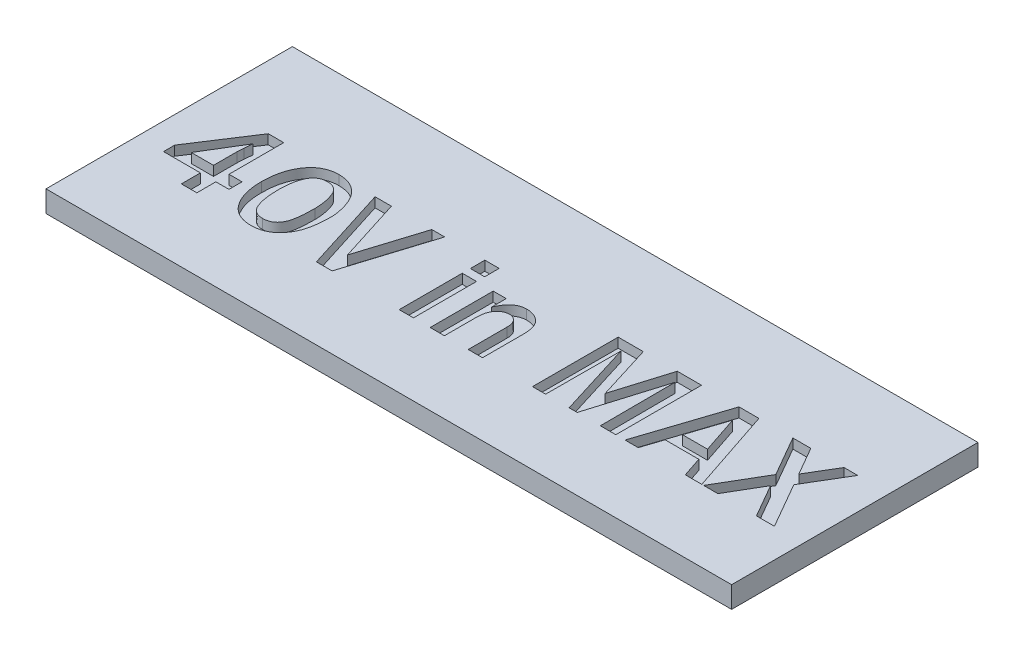
from build123d import *

# Parameters (mm, degrees)
SKETCH1_W           = 32
SKETCH1_H           = 11.5
BOSS_EXTRUDE1_DEPTH = 1
SKETCH2_W           = 0.666666667
SKETCH2_H           = 0.677083333
SKETCH2_H_2         = 2.944444444
CUT_EXTRUDE1_DEPTH  = 0.45


with BuildPart() as part:
    # Sketch1 → Boss-Extrude1 (new body)
    with BuildSketch(Plane(origin=(0, 0, 0), x_dir=(1, 0, 0), z_dir=(0, 1, 0))):
        with Locations((-3.777906977, 3.556976744)):
            Rectangle(SKETCH1_W, SKETCH1_H)
    extrude(amount=BOSS_EXTRUDE1_DEPTH)

    # Sketch2 → Cut-Extrude1 (cut)
    with BuildSketch(Plane(origin=(0, 1, 0), x_dir=(1, 0, 0), z_dir=(0, 1, 0))):
        Polygon((-16.097653065, 1.166505998), (-16.819875288, 1.166505998), (-16.819875288, 2.055394887), (-18.54209751, 2.055394887), (-18.54209751, 2.578832387), (-16.819875288, 5.222061553), (-16.097653065, 5.222061553), (-16.097653065, 2.666505998), (-15.486541954, 2.666505998), (-15.486541954, 2.055394887), (-16.097653065, 2.055394887), align=None)
        with BuildLine():
            Line((-16.766923899, 4.458172665), (-17.857201677, 2.666505998))
            Line((-17.857201677, 2.666505998), (-16.819875288, 2.666505998))
            Line((-16.819875288, 2.666505998), (-16.819875288, 3.762860165))
            add(Edge.make_bspline(
                [(-16.819875288, 3.762860165), (-16.819319866, 3.818177081), (-16.818265444, 3.923191713), (-16.807573902, 4.027658042), (-16.802514177, 4.077096276)],
                knots=[0, 0, 0, 0, 0.000165855, 0.000314863, 0.000314863, 0.000314863, 0.000314863], degree=3))
            Line((-16.802514177, 4.077096276), (-16.766923899, 4.458172665))
        make_face(mode=Mode.SUBTRACT)
        with BuildLine():
            add(Edge.make_bspline(
                [(-13.525604454, 1.110950442), (-13.58475032, 1.112416739), (-13.69993031, 1.115272188), (-13.867311675, 1.143345758), (-14.024764425, 1.186921434), (-14.171217374, 1.250090903), (-14.307963868, 1.329793669), (-14.433242579, 1.428538986), (-14.547587952, 1.545551389), (-14.651419625, 1.678072498), (-14.742591078, 1.825250167), (-14.823443277, 1.982113771), (-14.891702778, 2.14905314), (-14.945532916, 2.325724063), (-14.989431197, 2.511490669), (-15.020377902, 2.707022486), (-15.038743335, 2.912388636), (-15.040963905, 3.052463013), (-15.04209751, 3.123971276)],
                knots=[0, 0, 0, 0, 0.000177296, 0.000345264, 0.000507665, 0.000666327, 0.00082235, 0.000981242, 0.001143292, 0.001312081, 0.001485251, 0.001661896, 0.001840987, 0.002025493, 0.002215415, 0.002413212, 0.002618882, 0.002833378, 0.002833378, 0.002833378, 0.002833378], degree=3))
            add(Edge.make_bspline(
                [(-15.04209751, 3.123971276), (-15.041153805, 3.20098927), (-15.039309128, 3.351537844), (-15.018441162, 3.571240529), (-14.987038215, 3.77960434), (-14.94187967, 3.976378482), (-14.884131081, 4.161821209), (-14.81238597, 4.335226182), (-14.7295261, 4.497836364), (-14.632240218, 4.646553801), (-14.525090061, 4.781236686), (-14.408509436, 4.899747852), (-14.281974225, 4.999121269), (-14.146817076, 5.080985248), (-14.002752645, 5.14478328), (-13.849577359, 5.189838493), (-13.687781108, 5.217541971), (-13.576932061, 5.22053502), (-13.520396121, 5.222061553)],
                knots=[0, 0, 0, 0, 0.000230983, 0.000451506, 0.000661443, 0.00086275, 0.001056577, 0.001243411, 0.001425106, 0.001603275, 0.001775582, 0.001940697, 0.002100808, 0.002256974, 0.002413595, 0.002572069, 0.002734898, 0.002904391, 0.002904391, 0.002904391, 0.002904391], degree=3))
            add(Edge.make_bspline(
                [(-13.520396121, 5.222061553), (-13.479285272, 5.221151515), (-13.398617098, 5.219365828), (-13.280036207, 5.207589042), (-13.166744201, 5.185288359), (-13.05768719, 5.156132894), (-12.953791302, 5.117871372), (-12.854376954, 5.071752064), (-12.760806273, 5.015602292), (-12.671127836, 4.95239784), (-12.587214261, 4.881185708), (-12.508927868, 4.803404693), (-12.435160343, 4.720000327), (-12.368859188, 4.62837832), (-12.307095226, 4.53097836), (-12.250293726, 4.427426846), (-12.200064675, 4.316680954), (-12.141489221, 4.162589631), (-12.079938272, 3.969091489), (-12.027082946, 3.739444771), (-11.992652943, 3.51708515), (-11.988550846, 3.370905857), (-11.986541954, 3.299318498)],
                knots=[0, 0, 0, 0, 0.00012334, 0.00024202, 0.000356935, 0.000469384, 0.000580332, 0.000688676, 0.00079765, 0.000907239, 0.001017495, 0.001127369, 0.0012381, 0.001351127, 0.001466238, 0.001583942, 0.001705138, 0.001830718, 0.00207835, 0.002313555, 0.002537227, 0.002751889, 0.002751889, 0.002751889, 0.002751889], degree=3))
            add(Edge.make_bspline(
                [(-11.986541954, 3.299318498), (-11.98713147, 3.242023209), (-11.988284143, 3.129994273), (-11.994659573, 2.96576509), (-12.008221558, 2.809504406), (-12.024945941, 2.660844751), (-12.047940584, 2.520220695), (-12.073866235, 2.387191721), (-12.107641665, 2.262633674), (-12.144523444, 2.145041206), (-12.187302867, 2.033938597), (-12.236111294, 1.928429265), (-12.29086582, 1.827979369), (-12.350563304, 1.731658456), (-12.417832088, 1.641761681), (-12.489852822, 1.556091433), (-12.568569101, 1.476131629), (-12.65220436, 1.400800953), (-12.741333024, 1.331575474), (-12.83723307, 1.272592726), (-12.938742002, 1.222758889), (-13.045766021, 1.182158064), (-13.158040506, 1.14967594), (-13.27579107, 1.127656323), (-13.39878869, 1.113034428), (-13.482736239, 1.111654903), (-13.525604454, 1.110950442)],
                knots=[0, 0, 0, 0, 0.000171895, 0.000336104, 0.000492896, 0.000642345, 0.00078477, 0.000920281, 0.001048721, 0.001171709, 0.001289873, 0.001405612, 0.001520198, 0.001632915, 0.001745244, 0.001856724, 0.001968444, 0.002081551, 0.002194231, 0.002306489, 0.002418683, 0.002532984, 0.002649478, 0.002768819, 0.002892, 0.003020546, 0.003020546, 0.003020546, 0.003020546], degree=3))
        make_face()
        with BuildLine():
            add(Edge.make_bspline(
                [(-13.521264177, 1.666505998), (-13.496643054, 1.666931477), (-13.448108708, 1.667770201), (-13.377196958, 1.676589255), (-13.309939406, 1.691074101), (-13.246817934, 1.712509882), (-13.187073399, 1.738213221), (-13.13048331, 1.769618111), (-13.078682983, 1.808282622), (-13.01295047, 1.866668258), (-12.94032026, 1.954525849), (-12.8693224, 2.07746391), (-12.812390069, 2.218199053), (-12.779982479, 2.348638854), (-12.760015943, 2.463151969), (-12.746144555, 2.55897472), (-12.733966062, 2.66286115), (-12.724527287, 2.774901706), (-12.717874726, 2.894756557), (-12.712743606, 3.022375694), (-12.708978914, 3.158092633), (-12.708837215, 3.25128332), (-12.708764177, 3.299318498)],
                knots=[0, 0, 0, 0, 7.3831e-05, 0.000145539, 0.000213988, 0.000279869, 0.000345181, 0.000408923, 0.00047351, 0.000538678, 0.000672384, 0.000813223, 0.000963135, 0.001126304, 0.001215359, 0.00131185, 0.001416724, 0.001529109, 0.001649102, 0.001776812, 0.001912273, 0.002056373, 0.002056373, 0.002056373, 0.002056373], degree=3))
            add(Edge.make_bspline(
                [(-12.708764177, 3.299318498), (-12.710713247, 3.379863321), (-12.714577217, 3.539540927), (-12.747062813, 3.775395566), (-12.798236877, 4.005332113), (-12.857650421, 4.190254339), (-12.916669518, 4.329333348), (-12.973108728, 4.419371897), (-13.038782009, 4.49559848), (-13.113137202, 4.559843707), (-13.198781455, 4.607620479), (-13.293499267, 4.641671651), (-13.397357117, 4.66287691), (-13.469944595, 4.665271299), (-13.507375288, 4.666505998)],
                knots=[0, 0, 0, 0, 0.000241544, 0.000478854, 0.000712827, 0.000947531, 0.001060612, 0.001165139, 0.001264849, 0.001361546, 0.001458341, 0.001557201, 0.001662579, 0.001774773, 0.001774773, 0.001774773, 0.001774773], degree=3))
            add(Edge.make_bspline(
                [(-13.507375288, 4.666505998), (-13.540149623, 4.665322944), (-13.604150625, 4.663012703), (-13.697145848, 4.645408656), (-13.783731749, 4.615917695), (-13.863768786, 4.574129902), (-13.938375022, 4.522362183), (-14.004760488, 4.456248174), (-14.065728939, 4.379855777), (-14.119298372, 4.291090914), (-14.16753063, 4.19160695), (-14.207237465, 4.079741384), (-14.243764674, 3.957213909), (-14.270054495, 3.822140872), (-14.29334613, 3.676043135), (-14.308087909, 3.518020184), (-14.317907492, 3.348344147), (-14.319204675, 3.231336432), (-14.319875288, 3.170846276)],
                knots=[0, 0, 0, 0, 9.8278e-05, 0.000191916, 0.00028278, 0.000371687, 0.000462002, 0.000554082, 0.000651691, 0.000754565, 0.000864439, 0.000982803, 0.001110269, 0.001247655, 0.001395224, 0.001553981, 0.001723521, 0.001904978, 0.001904978, 0.001904978, 0.001904978], degree=3))
            add(Edge.make_bspline(
                [(-14.319875288, 3.170846276), (-14.319379046, 3.115861224), (-14.318409544, 3.008437498), (-14.310750353, 2.851166742), (-14.29692671, 2.702029908), (-14.277685624, 2.561347368), (-14.254722833, 2.428776598), (-14.225593134, 2.304556557), (-14.189305088, 2.188992997), (-14.15064484, 2.080992056), (-14.10375965, 1.983424247), (-14.046523913, 1.898818396), (-13.981172741, 1.826590781), (-13.90637306, 1.767631682), (-13.822534435, 1.72159744), (-13.729605977, 1.690258318), (-13.628405004, 1.669082766), (-13.557839246, 1.667385639), (-13.521264177, 1.666505998)],
                knots=[0, 0, 0, 0, 0.000164951, 0.000322263, 0.000472213, 0.000614129, 0.000748139, 0.000875731, 0.000996544, 0.001111351, 0.001219663, 0.001320301, 0.001416765, 0.001510716, 0.001604727, 0.001702185, 0.001803988, 0.001913532, 0.001913532, 0.001913532, 0.001913532], degree=3))
        make_face(mode=Mode.SUBTRACT)
        Polygon((-9.782548899, 1.166505998), (-10.515187788, 1.166505998), (-11.778208621, 5.166505998), (-11.016055843, 5.166505998), (-10.069875288, 2.16997822), (-9.129771121, 5.166505998), (-8.528208621, 5.166505998), align=None)
        with Locations((-6.319875288, 4.827964332)):
            Rectangle(SKETCH2_W, SKETCH2_H)
        with Locations((-6.319875288, 2.63872822)):
            Rectangle(SKETCH2_W, SKETCH2_H_2)
        with BuildLine():
            Line((-2.764319732, 1.166505998), (-3.430986399, 1.166505998))
            Line((-3.430986399, 1.166505998), (-3.430986399, 2.978137942))
            add(Edge.make_bspline(
                [(-3.430986399, 2.978137942), (-3.432502597, 3.023125825), (-3.435366678, 3.108107418), (-3.460397998, 3.226810455), (-3.501635682, 3.32898112), (-3.561743782, 3.411143123), (-3.632689535, 3.475686161), (-3.712262651, 3.521200448), (-3.798670531, 3.5512961), (-3.85926295, 3.554009855), (-3.890187788, 3.555394887)],
                knots=[0, 0, 0, 0, 0.000134828, 0.000254689, 0.000362062, 0.000462771, 0.000557425, 0.000647653, 0.000736318, 0.00082874, 0.00082874, 0.00082874, 0.00082874], degree=3))
            add(Edge.make_bspline(
                [(-3.890187788, 3.555394887), (-3.911647316, 3.554764453), (-3.953957961, 3.553521458), (-4.016519871, 3.542451438), (-4.076958369, 3.525544059), (-4.135497758, 3.500571148), (-4.191353193, 3.468351916), (-4.246141882, 3.429884787), (-4.297609284, 3.383316713), (-4.348609858, 3.331695112), (-4.394319193, 3.272091942), (-4.433746402, 3.204847599), (-4.467458087, 3.130984346), (-4.495455629, 3.049962035), (-4.515633687, 2.961376193), (-4.531577907, 2.86636454), (-4.539777471, 2.763869106), (-4.54130609, 2.693427511), (-4.54209751, 2.656957387)],
                knots=[0, 0, 0, 0, 6.433e-05, 0.000126836, 0.000190031, 0.000252266, 0.00031719, 0.000383185, 0.000452678, 0.000525118, 0.000600644, 0.000677313, 0.000758494, 0.000843869, 0.000933983, 0.001030739, 0.001132672, 0.001242102, 0.001242102, 0.001242102, 0.001242102], degree=3))
            Line((-4.54209751, 2.656957387), (-4.54209751, 1.166505998))
            Line((-4.54209751, 1.166505998), (-5.208764177, 1.166505998))
            Line((-5.208764177, 1.166505998), (-5.208764177, 4.110950442))
            Line((-5.208764177, 4.110950442), (-4.601125288, 4.110950442))
            Line((-4.601125288, 4.110950442), (-4.601125288, 3.425186553))
            add(Edge.make_bspline(
                [(-4.601125288, 3.425186553), (-4.574524022, 3.483649153), (-4.523492052, 3.595804027), (-4.431512761, 3.747541837), (-4.33076832, 3.875901239), (-4.223388721, 3.983056127), (-4.105191157, 4.064941513), (-3.979551532, 4.124184175), (-3.845325596, 4.160484183), (-3.752968636, 4.164480548), (-3.70616001, 4.166505998)],
                knots=[0, 0, 0, 0, 0.000192575, 0.000369437, 0.000530767, 0.000681161, 0.00082275, 0.000959832, 0.001096268, 0.00123648, 0.00123648, 0.00123648, 0.00123648], degree=3))
            add(Edge.make_bspline(
                [(-3.70616001, 4.166505998), (-3.674286572, 4.166017368), (-3.611452463, 4.1650541), (-3.519175639, 4.15208106), (-3.430374243, 4.133058664), (-3.344758875, 4.107578522), (-3.263451731, 4.071961862), (-3.185465509, 4.029756687), (-3.11106731, 3.979416428), (-3.039477444, 3.922738989), (-2.973661489, 3.855639547), (-2.916509917, 3.776567128), (-2.870460922, 3.685211777), (-2.830629182, 3.583401422), (-2.801148458, 3.469681312), (-2.779538185, 3.344563249), (-2.766590323, 3.208154887), (-2.765095383, 3.1132941), (-2.764319732, 3.064075442)],
                knots=[0, 0, 0, 0, 9.5549e-05, 0.000188362, 0.00027894, 0.000367906, 0.000455786, 0.000544739, 0.000633578, 0.000724951, 0.000818258, 0.000914628, 0.00101635, 0.001124356, 0.001242059, 0.001368074, 0.001504979, 0.001652613, 0.001652613, 0.001652613, 0.001652613], degree=3))
            Line((-2.764319732, 3.064075442), (-2.764319732, 1.166505998))
        make_face()
        Polygon((3.45790249, 1.166505998), (2.735680268, 1.166505998), (2.721791379, 4.668242109), (1.657555268, 1.166505998), (1.279951101, 1.166505998), (0.194013601, 4.668242109), (0.180124712, 1.166505998), (-0.430986399, 1.166505998), (-0.430986399, 5.166505998), (0.740020546, 5.166505998), (1.541235823, 2.588380998), (2.32508999, 5.166505998), (3.45790249, 5.166505998), align=None)
        Polygon((7.471791379, 1.166505998), (6.701826101, 1.166505998), (6.38758999, 2.110950442), (4.815541379, 2.110950442), (4.503909435, 1.166505998), (3.888458046, 1.166505998), (5.207034435, 5.166505998), (6.138458046, 5.166505998), align=None)
        Polygon((6.182728879, 2.722061553), (5.596791379, 4.480742109), (5.016062212, 2.722061553), align=None, mode=Mode.SUBTRACT)
        Polygon((10.860680268, 1.166505998), (10.022138601, 1.166505998), (9.130645546, 2.715985165), (8.221791379, 1.166505998), (7.555124712, 1.166505998), (8.80165249, 3.290637942), (7.721791379, 5.166505998), (8.560333046, 5.166505998), (9.319881657, 3.847061553), (10.108944157, 5.166505998), (10.749569157, 5.166505998), (9.633249712, 3.300186553), align=None)
    extrude(amount=-CUT_EXTRUDE1_DEPTH, mode=Mode.SUBTRACT)


solid = part.part
